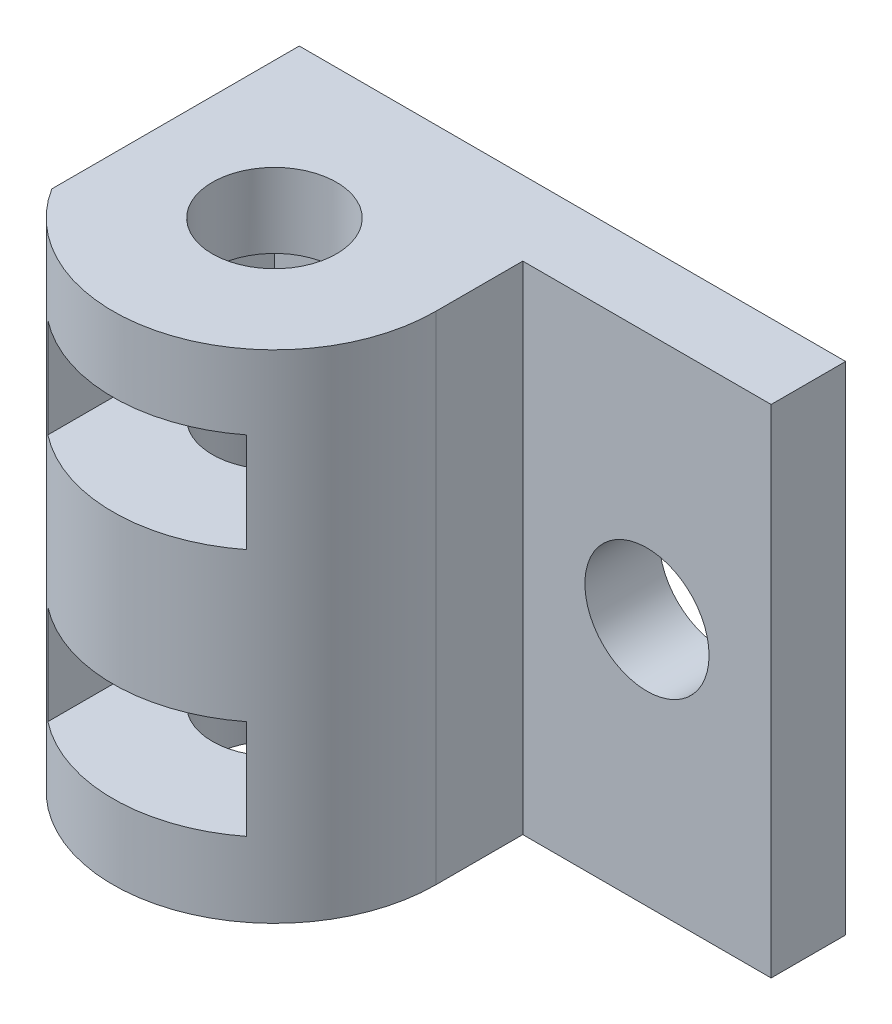
from build123d import *

# Parameters (mm, degrees)
SKETCH1_W           = 23
SKETCH1_H           = 20
BOSS_EXTRUDE1_DEPTH = 3
BOSS_EXTRUDE2_DEPTH = 20
CUT_EXTRUDE2_DEPTH  = 2
LPATTERN2_COUNT     = 2
LPATTERN2_PITCH     = 10
SKETCH6_R           = 2.5
CUT_EXTRUDE3_DEPTH  = 4
SKETCH7_W           = 15.359271736
SKETCH7_H           = 20
CUT_EXTRUDE4_DEPTH  = 1


with BuildPart() as part:
    # Sketch1 → Boss-Extrude1 (new body)
    with BuildSketch(Plane.XY):
        with Locations((0.940520446, -4.763011152)):
            Rectangle(SKETCH1_W, SKETCH1_H)
    extrude(amount=BOSS_EXTRUDE1_DEPTH)

    # Sketch2 → Boss-Extrude2 (add, through all)
    with BuildSketch(Plane(origin=(0, 5.236988848, 0), x_dir=(1, 0, 0), z_dir=(0, 1, 0))):
        with BuildLine():
            ThreePointArc((1.417746021, -3), (-0.936980555, -0.799122875), (-4.059479554, 0))
            Line((-4.059479554, 0), (-4.059479554, -3))
            Line((-4.059479554, -3), (1.417746021, -3))
        make_face()
        with BuildLine():
            Line((-4.059479554, -3), (-4.059479554, 0))
            ThreePointArc((-4.059479554, 0), (-7.181978553, -0.799122875), (-9.536705129, -3))
            Line((-9.536705129, -3), (-4.059479554, -3))
        make_face()
        with BuildLine():
            Line((1.417746021, -3), (-4.059479554, -3))
            Line((-4.059479554, -3), (-4.059479554, -4))
            ThreePointArc((-4.059479554, -4), (-2.291712601, -4.732233047), (-1.559479554, -6.5))
            ThreePointArc((-1.559479554, -6.5), (-2.291712601, -8.267766953), (-4.059479554, -9))
            Line((-4.059479554, -9), (-4.059479554, -13))
            ThreePointArc((-4.059479554, -13), (0.536714524, -11.096194078), (2.440520446, -6.5))
            ThreePointArc((2.440520446, -6.5), (2.179589537, -4.676811342), (1.417746021, -3))
        make_face()
        with BuildLine():
            Line((-4.059479554, -4), (-4.059479554, -3))
            Line((-4.059479554, -3), (-9.536705129, -3))
            ThreePointArc((-9.536705129, -3), (-10.298548645, -4.676811342), (-10.559479554, -6.5))
            ThreePointArc((-10.559479554, -6.5), (-8.655673632, -11.096194078), (-4.059479554, -13))
            Line((-4.059479554, -13), (-4.059479554, -9))
            ThreePointArc((-4.059479554, -9), (-6.559479554, -6.5), (-4.059479554, -4))
        make_face()
        with BuildLine():
            ThreePointArc((-10.559479554, -6.5), (-10.298548645, -4.676811342), (-9.536705129, -3))
            Line((-9.536705129, -3), (-10.559479554, -3))
            Line((-10.559479554, -3), (-10.559479554, -6.5))
        make_face()
        with BuildLine():
            Line((2.440520446, -3), (1.417746021, -3))
            ThreePointArc((1.417746021, -3), (2.179589537, -4.676811342), (2.440520446, -6.5))
            Line((2.440520446, -6.5), (2.440520446, -3))
        make_face()
    extrude(amount=-BOSS_EXTRUDE2_DEPTH)

    # Sketch4 → Cut-Extrude2 (cut, symmetric)
    with BuildSketch(Plane(origin=(0, 0.236988848, 0), x_dir=(-1, 0, 0), z_dir=(0, -1, 0))):
        Polygon((0.059479554, -2.5), (8.059479554, -2.5), (8.059479554, -10.5), (8.059479554, -14.57083766), (0.059479554, -14.57083766), (0.059479554, -10.5), align=None)
    cut_extrude2 = extrude(amount=CUT_EXTRUDE2_DEPTH, both=True, mode=Mode.SUBTRACT)

    # LPattern2: Cut-Extrude2 ×2
    with Locations(*[(0, -i * LPATTERN2_PITCH, 0) for i in range(1, LPATTERN2_COUNT)]):
        add(cut_extrude2, mode=Mode.SUBTRACT)

    # Sketch6 → Cut-Extrude3 (cut)
    with BuildSketch(Plane.XY.offset(3)):
        with Locations((7.440520446, -4.763011152)):
            Circle(SKETCH6_R)
    extrude(amount=-CUT_EXTRUDE3_DEPTH, mode=Mode.SUBTRACT)

    # Sketch7 → Cut-Extrude4 (cut)
    with BuildSketch(Plane.ZY.offset(10.559479554)):
        with Locations((7.679635868, -4.763011152)):
            Rectangle(SKETCH7_W, SKETCH7_H)
    extrude(amount=-CUT_EXTRUDE4_DEPTH, mode=Mode.SUBTRACT)


solid = part.part
